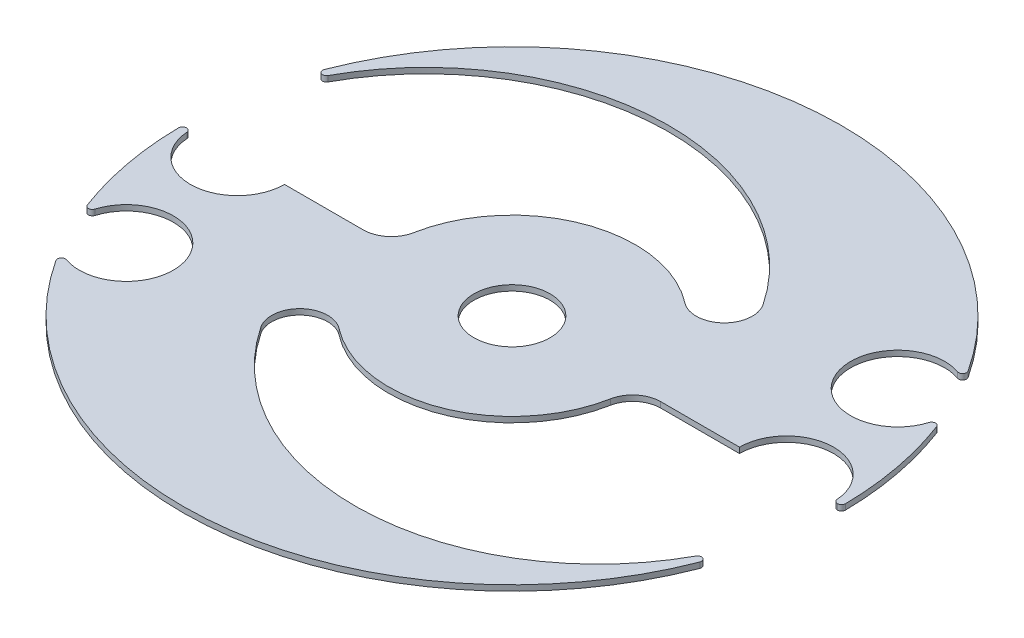
from build123d import *

# Parameters (mm, degrees)
BOSS_EXTRUDE1_DEPTH = 1
SKETCH3_R           = 6.8
CUT_EXTRUDE1_DEPTH  = 10


with BuildPart() as part:
    # Sketch1 → Boss-Extrude1 (new body)
    with BuildSketch(Plane(origin=(0, 0, 0), x_dir=(1, 0, 0), z_dir=(0, 1, 0))):
        with BuildLine():
            Line((-58.095782979, 0), (-58.073036978, 0))
            ThreePointArc((-58.073036978, 0), (-57.597480623, -0.18634043), (-57.375111056, -0.646153846))
            ThreePointArc((-57.375111056, -0.646153846), (-48.676683494, -8.393775458), (-40.6, 0))
            Line((-40.6, 0), (-26.532998323, 0))
            ThreePointArc((-26.532998323, 0), (-23.34157463, 1.150998205), (-21.619480115, 4.074074074))
            ThreePointArc((-21.619480115, 4.074074074), (-7.819670385, 20.563383843), (13.44973545, 17.409899952))
            ThreePointArc((13.44973545, 17.409899952), (19.920363156, 17.713546888), (20.660984848, 24.148817192))
            ThreePointArc((20.660984848, 24.148817192), (-17.408618139, 43.353494129), (-53.539393939, 20.711026772))
            ThreePointArc((-53.539393939, 20.711026772), (-54.448939175, 20.409991078), (-54.807009858, 21.298630718))
            ThreePointArc((-54.807009858, 21.298630718), (-6.094732075, 58.483281722), (49.237842792, 32.141481565))
            ThreePointArc((49.237842792, 32.141481565), (49.203069762, 31.327605826), (48.421551499, 31.097753513))
            ThreePointArc((48.421551499, 31.097753513), (38.168934267, 19.364205559), (53.692695632, 20.707760837))
            ThreePointArc((53.692695632, 20.707760837), (54.339746442, 21.20266298), (55.017049011, 20.750043811))
            ThreePointArc((55.017049011, 20.750043811), (57.781950674, 10.894318531), (58.795732172, 0.708433735))
            ThreePointArc((58.795732172, 0.708433735), (58.593730574, 0.208016065), (58.095782979, 0))
            Line((58.095782979, 0), (58.073036978, 0))
            ThreePointArc((58.073036978, 0), (57.597480623, 0.18634043), (57.375111056, 0.646153846))
            ThreePointArc((57.375111056, 0.646153846), (48.676683494, 8.393775458), (40.6, 0))
            Line((40.6, 0), (26.532998323, 0))
            ThreePointArc((26.532998323, 0), (23.34157463, -1.150998205), (21.619480115, -4.074074074))
            ThreePointArc((21.619480115, -4.074074074), (7.819670385, -20.563383843), (-13.44973545, -17.409899952))
            ThreePointArc((-13.44973545, -17.409899952), (-19.920363156, -17.713546888), (-20.660984848, -24.148817192))
            ThreePointArc((-20.660984848, -24.148817192), (17.408618139, -43.353494129), (53.539393939, -20.711026772))
            ThreePointArc((53.539393939, -20.711026772), (54.448939175, -20.409991078), (54.807009858, -21.298630718))
            ThreePointArc((54.807009858, -21.298630718), (6.094732075, -58.483281722), (-49.237842792, -32.141481565))
            ThreePointArc((-49.237842792, -32.141481565), (-49.203069762, -31.327605826), (-48.421551499, -31.097753513))
            ThreePointArc((-48.421551499, -31.097753513), (-38.168934267, -19.364205559), (-53.692695632, -20.707760837))
            ThreePointArc((-53.692695632, -20.707760837), (-54.339746442, -21.20266298), (-55.017049011, -20.750043811))
            ThreePointArc((-55.017049011, -20.750043811), (-57.781950674, -10.894318531), (-58.795732172, -0.708433735))
            ThreePointArc((-58.795732172, -0.708433735), (-58.593730574, -0.208016065), (-58.095782979, 0))
        make_face()
    extrude(amount=BOSS_EXTRUDE1_DEPTH)

    # Sketch3 → Cut-Extrude1 (cut)
    with BuildSketch(Plane(origin=(0, 1, 0), x_dir=(1, 0, 0), z_dir=(0, 1, 0))):
        Circle(SKETCH3_R)
    extrude(amount=-CUT_EXTRUDE1_DEPTH, mode=Mode.SUBTRACT)


solid = part.part
